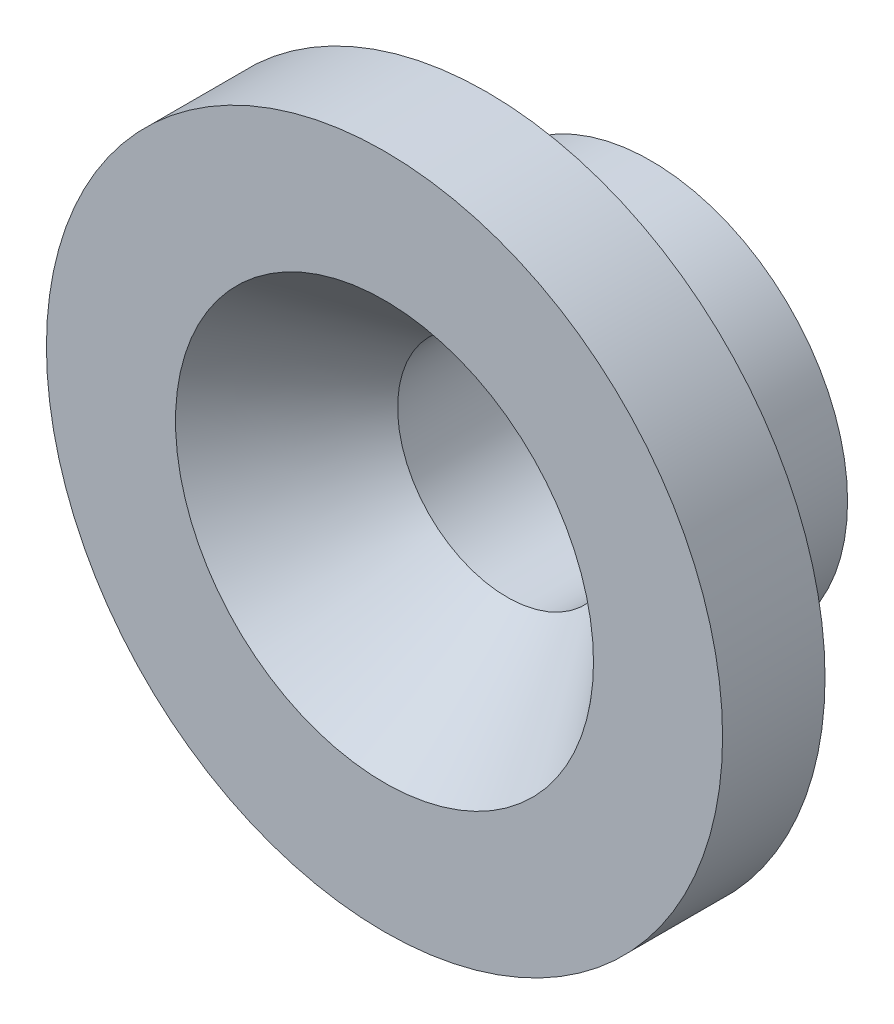
from build123d import *

# Parameters (mm, degrees)
SKETCH1_R           = 4.8
BOSS_EXTRUDE1_DEPTH = 4
SKETCH2_R           = 8.25
BOSS_EXTRUDE2_DEPTH = 2.5
SKETCH3_R           = 2.675
CUT_EXTRUDE1_DEPTH  = 6.5
SKETCH4_R           = 5.1
CUT_EXTRUDE2_DEPTH  = 3
CUT_EXTRUDE2_TAPER  = 39


with BuildPart() as part:
    # Sketch1 → Boss-Extrude1 (new body)
    with BuildSketch(Plane.XY):
        Circle(SKETCH1_R)
    extrude(amount=BOSS_EXTRUDE1_DEPTH)

    # Sketch2 → Boss-Extrude2 (add)
    with BuildSketch(Plane.XY.offset(4)):
        Circle(SKETCH2_R)
    extrude(amount=BOSS_EXTRUDE2_DEPTH)

    # Sketch3 → Cut-Extrude1 (cut)
    with BuildSketch(Plane.XY.offset(6.5)):
        Circle(SKETCH3_R)
    extrude(amount=-CUT_EXTRUDE1_DEPTH, mode=Mode.SUBTRACT)

    # Sketch4 → Cut-Extrude2 (cut)
    with BuildSketch(Plane.XY.offset(6.5)):
        Circle(SKETCH4_R)
    extrude(amount=-CUT_EXTRUDE2_DEPTH, taper=CUT_EXTRUDE2_TAPER, mode=Mode.SUBTRACT)


solid = part.part
